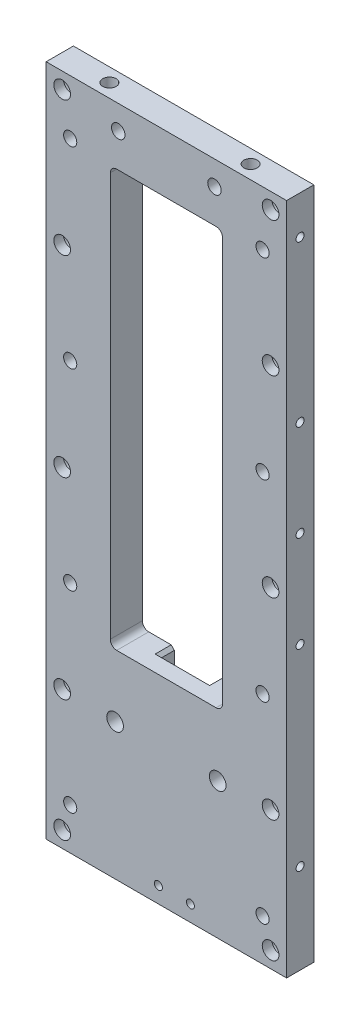
from build123d import *

# Parameters (mm, degrees)
BOSS_EXTRUDE1_DEPTH                                 = 10
M5_TAPPED_HOLE1_D                                   = 4.1
M5_TAPPED_HOLE1_DEPTH                               = 14
M5_TAPPED_HOLE1_TIP                                 = 1.231764269
CUT_EXTRUDE1_REACH                                  = 12
SKETCH4_W                                           = 35
SKETCH4_H                                           = 130
FILLET1_R                                           = 2
SKETCH6_W                                           = 15
SKETCH6_H                                           = 210
CUT_EXTRUDE2_DEPTH                                  = 1.5
SKETCH7_W                                           = 45
SKETCH7_H                                           = 15
CUT_EXTRUDE3_DEPTH                                  = 1.5
CBORE_FOR_M5_HEX_SOCKET_HEAD_CAP_SCREW1_D           = 5.2
CBORE_FOR_M5_HEX_SOCKET_HEAD_CAP_SCREW1_CBORE_D     = 8.5
CBORE_FOR_M5_HEX_SOCKET_HEAD_CAP_SCREW1_CBORE_DEPTH = 5.5
M5_TAPPED_HOLE2_D                                   = 4.2
M5_TAPPED_HOLE2_DEPTH                               = 16
M5_TAPPED_HOLE2_TIP                                 = 1.2618073
M5_TAPPED_HOLE3_D                                   = 4.2
M5_TAPPED_HOLE3_DEPTH                               = 103.56
M5_TAPPED_HOLE3_TIP                                 = 1.2618073
SKETCH14_W                                          = 45
SKETCH14_H                                          = 18
CUT_EXTRUDE4_DEPTH                                  = 5
FILLET2_R                                           = 2
SKETCH15_W                                          = 15
SKETCH15_H                                          = 18
CUT_EXTRUDE6_DEPTH                                  = 5
TAP_DRILL_FOR_M5_TAP1_D                             = 5.2
TAP_DRILL_FOR_M5_TAP1_DEPTH                         = 46
TAP_DRILL_FOR_M5_TAP1_CSINK_D                       = 6
TAP_DRILL_FOR_M5_TAP1_CSINK_ANGLE                   = 90
TAP_DRILL_FOR_M5_TAP1_TIP                           = 1.562237609
CHAMFER1_SIZE                                       = 1
M3_TAPPED_HOLE1_AT_2_COUNT                          = 2
M3_TAPPED_HOLE1_AT_2_PITCH                          = 50
M3_TAPPED_HOLE1_AT_3_COUNT                          = 2
M3_TAPPED_HOLE1_AT_3_PITCH                          = 80
M3_TAPPED_HOLE1_AT_4_COUNT                          = 2
M3_TAPPED_HOLE1_AT_4_PITCH                          = 110
M3_TAPPED_HOLE1_AT_5_COUNT                          = 2
M3_TAPPED_HOLE1_AT_5_PITCH                          = 170
M3_TAPPED_HOLE2_D                                   = 2.5


with BuildPart() as part:
    # Sketch1 → Boss-Extrude1 (new body)
    with BuildSketch(Plane.XY):
        Polygon((-37.5, 0), (0, 0), (37.5, 0), (37.5, 210), (0, 210), (-37.5, 210), align=None)
    extrude(amount=BOSS_EXTRUDE1_DEPTH)

    # M5 Tapped Hole1
    with Locations(Plane(origin=(30, 193, 0), x_dir=(-1, 0, 0), z_dir=(0, 0, -1))):
        with Locations((0, 0), (0, -60), (0, -120), (0, -180), (60, -180), (60, -120), (60, -60), (60, 0)):
            Hole(M5_TAPPED_HOLE1_D / 2, depth=M5_TAPPED_HOLE1_DEPTH)
            with Locations((0, 0, -(M5_TAPPED_HOLE1_DEPTH + M5_TAPPED_HOLE1_TIP / 2))):  # 118° drill point
                Cone(0, M5_TAPPED_HOLE1_D / 2, M5_TAPPED_HOLE1_TIP, mode=Mode.SUBTRACT)

    # Sketch4 → Cut-Extrude1 (cut, up to next)
    with BuildSketch(Plane(origin=(0, 0, 0), x_dir=(-1, 0, 0), z_dir=(0, 0, -1)), mode=Mode.PRIVATE) as cut_extrude1_sk1:
        with Locations((0, 127)):
            Rectangle(SKETCH4_W, SKETCH4_H)
    cut_extrude1_tool1 = extrude(cut_extrude1_sk1.sketch, amount=-CUT_EXTRUDE1_REACH, mode=Mode.PRIVATE) & part.part
    add(cut_extrude1_tool1.solids().sort_by_distance((0, 127, 0))[0], mode=Mode.SUBTRACT)

    # Fillet1
    fillet1_edges = [part.edges().sort_by_distance(p)[0] for p in [
        (17.5, 62, 5),
        (17.5, 192, 5),
        (-17.5, 192, 5),
        (-17.5, 62, 5),
    ]]
    fillet(fillet1_edges, radius=FILLET1_R)

    # Sketch6 → Cut-Extrude2 (cut)
    with BuildSketch(Plane(origin=(0, 0, 0), x_dir=(-1, 0, 0), z_dir=(0, 0, -1))):
        with Locations((-30, 105)):
            Rectangle(SKETCH6_W, SKETCH6_H)
        with Locations((30, 105)):
            Rectangle(SKETCH6_W, SKETCH6_H)
    extrude(amount=-CUT_EXTRUDE2_DEPTH, mode=Mode.SUBTRACT)

    # Sketch7 → Cut-Extrude3 (cut)
    with BuildSketch(Plane(origin=(0, 0, 0), x_dir=(-1, 0, 0), z_dir=(0, 0, -1))):
        with Locations((0, 202.5)):
            Rectangle(SKETCH7_W, SKETCH7_H)
    extrude(amount=-CUT_EXTRUDE3_DEPTH, mode=Mode.SUBTRACT)

    # CBORE for M5 Hex Socket Head Cap Screw1 (through all)
    with Locations(Plane(origin=(32.5, 205, 1.5), x_dir=(-1, 0, 0), z_dir=(0, 0, -1))):
        with Locations((0, 0), (0, -42), (0, -102), (0, -162), (0, -200), (65, -200), (65, -162), (65, -102), (65, -42), (65, 0)):
            CounterBoreHole(CBORE_FOR_M5_HEX_SOCKET_HEAD_CAP_SCREW1_D / 2, CBORE_FOR_M5_HEX_SOCKET_HEAD_CAP_SCREW1_CBORE_D / 2, CBORE_FOR_M5_HEX_SOCKET_HEAD_CAP_SCREW1_CBORE_DEPTH)

    # M5 Tapped Hole2
    with Locations(Plane(origin=(-22, 210, 5.75), x_dir=(0, 0, 1), z_dir=(0, 1, 0))):
        with Locations((0, 0), (0, 44)):
            Hole(M5_TAPPED_HOLE2_D / 2, depth=M5_TAPPED_HOLE2_DEPTH)
            with Locations((0, 0, -(M5_TAPPED_HOLE2_DEPTH + M5_TAPPED_HOLE2_TIP / 2))):  # 118° drill point
                Cone(0, M5_TAPPED_HOLE2_D / 2, M5_TAPPED_HOLE2_TIP, mode=Mode.SUBTRACT)

    # M5 Tapped Hole3
    with Locations(Plane(origin=(15, 202.5, 1.5), x_dir=(-1, 0, 0), z_dir=(0, 0, -1))):
        with Locations((0, 0), (30, 0)):
            Hole(M5_TAPPED_HOLE3_D / 2, depth=M5_TAPPED_HOLE3_DEPTH)
            with Locations((0, 0, -(M5_TAPPED_HOLE3_DEPTH + M5_TAPPED_HOLE3_TIP / 2))):  # 118° drill point
                Cone(0, M5_TAPPED_HOLE3_D / 2, M5_TAPPED_HOLE3_TIP, mode=Mode.SUBTRACT)

    # Sketch14 → Cut-Extrude4 (cut)
    with BuildSketch(Plane(origin=(0, 0, 0), x_dir=(-1, 0, 0), z_dir=(0, 0, -1))):
        with Locations((0, 44)):
            Rectangle(SKETCH14_W, SKETCH14_H)
    extrude(amount=-CUT_EXTRUDE4_DEPTH, mode=Mode.SUBTRACT)

    # Fillet2
    fillet2_edges = [part.edges().sort_by_distance(p)[0] for p in [
        (22.5, 35, 3.25),
        (22.5, 53, 3.25),
        (-22.5, 53, 3.25),
        (-22.5, 35, 3.25),
    ]]
    fillet(fillet2_edges, radius=FILLET2_R)

    # Sketch15 → Cut-Extrude6 (cut)
    with BuildSketch(Plane(origin=(0, 0, 0), x_dir=(-1, 0, 0), z_dir=(0, 0, -1))):
        with Locations((0, 62)):
            Rectangle(SKETCH15_W, SKETCH15_H)
    extrude(amount=-CUT_EXTRUDE6_DEPTH, mode=Mode.SUBTRACT)

    # Tap Drill for M5 Tap1
    with Locations(Plane(origin=(16, 42.5, 5), x_dir=(-1, 0, 0), z_dir=(0, 0, -1))):
        with Locations((0, 0), (32, 0)):
            CounterSinkHole(TAP_DRILL_FOR_M5_TAP1_D / 2, TAP_DRILL_FOR_M5_TAP1_CSINK_D / 2, depth=TAP_DRILL_FOR_M5_TAP1_DEPTH, counter_sink_angle=TAP_DRILL_FOR_M5_TAP1_CSINK_ANGLE)
            with Locations((0, 0, -(TAP_DRILL_FOR_M5_TAP1_DEPTH + TAP_DRILL_FOR_M5_TAP1_TIP / 2))):  # 118° drill point
                Cone(0, TAP_DRILL_FOR_M5_TAP1_D / 2, TAP_DRILL_FOR_M5_TAP1_TIP, mode=Mode.SUBTRACT)

    # Chamfer1
    chamfer1_edges = [part.edges().sort_by_distance(p)[0] for p in [
        (-22.5, 195, 0.75),
        (22.5, 195, 0.75),
        (-22.5, 35, 0.75),
        (-22.5, 53, 0.75),
        (22.5, 35, 0.75),
        (22.5, 53, 0.75),
        (7.5, 62, 2.5),
        (7.5, 53, 2.5),
        (-7.5, 62, 2.5),
        (-7.5, 53, 2.5),
    ]]
    chamfer(chamfer1_edges, length=CHAMFER1_SIZE)

    # Sketch20 → M3 Tapped Hole1 (revolve, cut)
    with BuildSketch(Plane(origin=(-37.5, 198, 5.8), x_dir=(0, 0, 1), z_dir=(0, 1, 0))):
        Polygon((0, 0), (0, 9.251075774), (1.25, 8.5), (1.25, 0), align=None)
    m3_tapped_hole1 = revolve(axis=Axis((-43.85, 198, 5.8), (1, 0, 0)), mode=Mode.SUBTRACT)

    # M3 Tapped Hole1 at 2: M3 Tapped Hole1 ×2
    with Locations(*[(0, -i * M3_TAPPED_HOLE1_AT_2_PITCH, 0) for i in range(1, M3_TAPPED_HOLE1_AT_2_COUNT)]):
        add(m3_tapped_hole1, mode=Mode.SUBTRACT)

    # M3 Tapped Hole1 at 3: M3 Tapped Hole1 ×2
    with Locations(*[(0, -i * M3_TAPPED_HOLE1_AT_3_PITCH, 0) for i in range(1, M3_TAPPED_HOLE1_AT_3_COUNT)]):
        add(m3_tapped_hole1, mode=Mode.SUBTRACT)

    # M3 Tapped Hole1 at 4: M3 Tapped Hole1 ×2
    with Locations(*[(0, -i * M3_TAPPED_HOLE1_AT_4_PITCH, 0) for i in range(1, M3_TAPPED_HOLE1_AT_4_COUNT)]):
        add(m3_tapped_hole1, mode=Mode.SUBTRACT)

    # M3 Tapped Hole1 at 5: M3 Tapped Hole1 ×2
    with Locations(*[(0, -i * M3_TAPPED_HOLE1_AT_5_PITCH, 0) for i in range(1, M3_TAPPED_HOLE1_AT_5_COUNT)]):
        add(m3_tapped_hole1, mode=Mode.SUBTRACT)

    # Mirror1: M3 Tapped Hole1 across plane
    add(m3_tapped_hole1.mirror(Plane(origin=(0, 0, 0), x_dir=(0, 0, 1), z_dir=(1, 0, 0))), mode=Mode.SUBTRACT)

    # Mirror1 copy 1 sketch → Mirror1 copy 1 (revolve, cut)
    with BuildSketch(Plane(origin=(37.5, 148, 5.8), x_dir=(0, 0, 1), z_dir=(0, 1, 0))):
        Polygon((0, 0), (0, -9.251075774), (1.25, -8.5), (1.25, 0), align=None)
    revolve(axis=Axis((43.85, 148, 5.8), (1, 0, 0)), mode=Mode.SUBTRACT)

    # Mirror1 copy 2 sketch → Mirror1 copy 2 (revolve, cut)
    with BuildSketch(Plane(origin=(37.5, 118, 5.8), x_dir=(0, 0, 1), z_dir=(0, 1, 0))):
        Polygon((0, 0), (0, -9.251075774), (1.25, -8.5), (1.25, 0), align=None)
    revolve(axis=Axis((43.85, 118, 5.8), (1, 0, 0)), mode=Mode.SUBTRACT)

    # Mirror1 copy 3 sketch → Mirror1 copy 3 (revolve, cut)
    with BuildSketch(Plane(origin=(37.5, 88, 5.8), x_dir=(0, 0, 1), z_dir=(0, 1, 0))):
        Polygon((0, 0), (0, -9.251075774), (1.25, -8.5), (1.25, 0), align=None)
    revolve(axis=Axis((43.85, 88, 5.8), (1, 0, 0)), mode=Mode.SUBTRACT)

    # Mirror1 copy 4 sketch → Mirror1 copy 4 (revolve, cut)
    with BuildSketch(Plane(origin=(37.5, 28, 5.8), x_dir=(0, 0, 1), z_dir=(0, 1, 0))):
        Polygon((0, 0), (0, -9.251075774), (1.25, -8.5), (1.25, 0), align=None)
    revolve(axis=Axis((43.85, 28, 5.8), (1, 0, 0)), mode=Mode.SUBTRACT)

    # M3 Tapped Hole2 (through all)
    with Locations(Plane(origin=(7.5, 5, 0), x_dir=(-1, 0, 0), z_dir=(0, 0, -1))):
        with Locations((0, 0), (10, 0)):
            Hole(M3_TAPPED_HOLE2_D / 2)


solid = part.part
